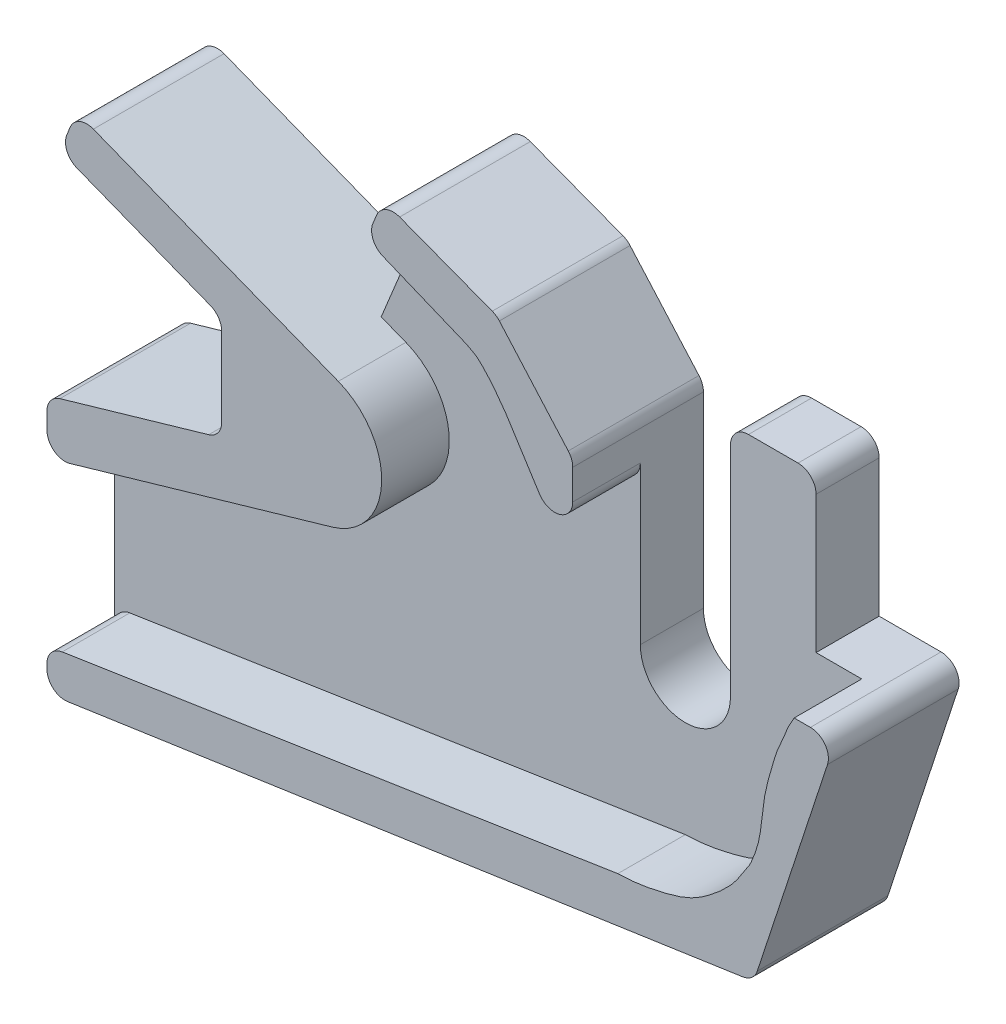
from build123d import *

# Parameters (mm, degrees)
BOSS_EXTRUDE1_DEPTH = 7
BOSS_EXTRUDE2_DEPTH = 14.5
FILLET1_R           = 2


with BuildPart() as part:
    # Sketch1 → Boss-Extrude1 (new body)
    with BuildSketch(Plane.XY):
        with BuildLine():
            Line((78.968274755, 42.187825254), (71.540745427, 53.865587102))
            add(Edge.make_bspline(
                [(68.390340924, 57.620496538), (68.602709936, 57.450222077), (69.775890669, 56.287697417), (70.767112906, 54.998035869), (71.540745427, 53.865587102)],
                knots=[0.224190465, 0.224190465, 0.224190465, 0.224190465, 0.35338295, 1, 1, 1, 1], degree=3))
            add(Edge.make_bspline(
                [(67.166812946, 58.333047532), (67.530665789, 58.148158455), (67.965619608, 57.94613578), (68.341003199, 57.660054826), (68.390340924, 57.620496538)],
                knots=[0, 0, 0, 0, 0.194176372, 0.224190465, 0.224190465, 0.224190465, 0.224190465], degree=3))
            Line((67.166812946, 58.333047532), (56.038116318, 62.903316899))
            Line((56.038116318, 62.903316899), (50.212333598, 48.717420333))
            Line((50.212333598, 48.717420333), (52.954647131, 47.643030748))
            ThreePointArc((52.954647131, 47.643030748), (57.760447877, 40.242237766), (52.301439007, 33.309224011))
            Line((52.301439007, 33.309224011), (20.622854325, 24.120186594))
            Line((20.622854325, 24.120186594), (20.622821101, 6.139939904))
            Line((20.622821101, 6.139939904), (20.622821101, 6.062388022))
            Line((20.622821101, 6.062388022), (83.968274755, 15.843555634))
            add(Edge.make_bspline(
                [(83.968274755, 15.843555634), (85.800365799, 15.861062532), (88.173725783, 16.289321284), (90.975797999, 17.070964386), (92.71201966, 17.824393939), (94.432142997, 19.052982354), (96.042680501, 20.454120962), (97.16419489, 21.752212783), (97.85208587, 22.923017738), (98.591547775, 23.89563478), (99.076744993, 25.078186891), (99.653721004, 26.703400446), (99.922417932, 28.680656555), (100.145652546, 30.848800013), (100.518866207, 32.862374789), (101.110135911, 34.645256352), (101.507154147, 36.227897201), (102.065937234, 37.400646368), (102.486280277, 38.406589289), (102.848421122, 39.429390424), (103.210900567, 39.990397653), (103.388377927, 40.31628874)],
                knots=[0, 0, 0, 0, 0.157855041, 0.207039447, 0.25109495, 0.320551145, 0.388512016, 0.435360012, 0.467800808, 0.505699215, 0.54027798, 0.577572476, 0.654531679, 0.711416671, 0.766136786, 0.830869277, 0.873613049, 0.906584734, 0.942749871, 0.967881323, 1, 1, 1, 1], degree=3))
            Line((103.388377927, 40.31628874), (103.535345735, 40.584708371))
            Line((103.535345735, 40.584708371), (98.468274755, 40.584708371))
            Line((98.468274755, 40.584708371), (98.468274755, 57.798688379))
            Line((98.468274755, 57.798688379), (88.968274755, 57.798688379))
            Line((88.968274755, 57.798688379), (88.968274755, 31.593555634))
            ThreePointArc((88.968274755, 31.593555634), (83.968274755, 26.593555634), (78.968274755, 31.593555634))
            Line((78.968274755, 31.593555634), (78.968274755, 42.187825254))
        make_face()
    extrude(amount=BOSS_EXTRUDE1_DEPTH)

    # Sketch1_3 → Boss-Extrude2 (add)
    with BuildSketch(Plane.XY):
        with BuildLine():
            Line((78.968274755, 42.187825254), (78.968274755, 53.145980791))
            Line((78.968274755, 53.145980791), (70.500822854, 62.754302183))
            Line((70.500822854, 62.754302183), (57.937552223, 67.52848103))
            Line((57.937552223, 67.52848103), (56.038116318, 62.903316899))
            Line((56.038116318, 62.903316899), (67.166812946, 58.333047532))
            add(Edge.make_bspline(
                [(67.166812946, 58.333047532), (67.530665789, 58.148158455), (68.216267043, 57.829717754), (69.737542808, 56.337591135), (70.767112906, 54.998035869), (71.540745427, 53.865587102)],
                knots=[0, 0, 0, 0, 0.194176372, 0.35338295, 1, 1, 1, 1], degree=3))
            Line((71.540745427, 53.865587102), (78.968274755, 42.187825254))
        make_face()
        with BuildLine():
            Line((108.098254598, 40.584708371), (103.535345735, 40.584708371))
            Line((103.535345735, 40.584708371), (103.388377927, 40.31628874))
            add(Edge.make_bspline(
                [(83.968274755, 15.843555634), (85.800365799, 15.861062532), (88.173725783, 16.289321284), (90.975797999, 17.070964386), (92.71201966, 17.824393939), (94.432142997, 19.052982354), (96.042680501, 20.454120962), (97.16419489, 21.752212783), (97.85208587, 22.923017738), (98.591547775, 23.89563478), (99.076744993, 25.078186891), (99.653721004, 26.703400446), (99.922417932, 28.680656555), (100.145652546, 30.848800013), (100.518866207, 32.862374789), (101.110135911, 34.645256352), (101.507154147, 36.227897201), (102.065937234, 37.400646368), (102.486280277, 38.406589289), (102.848421122, 39.429390424), (103.210900567, 39.990397653), (103.388377927, 40.31628874)],
                knots=[0, 0, 0, 0, 0.157855041, 0.207039447, 0.25109495, 0.320551145, 0.388512016, 0.435360012, 0.467800808, 0.505699215, 0.54027798, 0.577572476, 0.654531679, 0.711416671, 0.766136786, 0.830869277, 0.873613049, 0.906584734, 0.942749871, 0.967881323, 1, 1, 1, 1], degree=3))
            Line((83.968274755, 15.843555634), (20.622821101, 6.062388022))
            Line((20.622821101, 6.062388022), (20.622821101, 1.512651605))
            Line((20.622821101, 1.512651605), (99.055701616, 13.03519587))
            Line((99.055701616, 13.03519587), (108.098254598, 40.584708371))
        make_face()
        with BuildLine():
            Line((52.954647131, 47.643030748), (23.913290613, 59.020916827))
            Line((23.913290613, 59.020916827), (22.089364871, 54.365458215))
            Line((22.089364871, 54.365458215), (40.019787084, 47.340638243))
            Line((40.019787084, 47.340638243), (40.019787084, 35.746673468))
            Line((40.019787084, 35.746673468), (20.622854325, 30.120186594))
            Line((20.622854325, 30.120186594), (20.622854325, 24.120186594))
            Line((20.622854325, 24.120186594), (52.301439007, 33.309224011))
            ThreePointArc((52.301439007, 33.309224011), (57.760447877, 40.242237766), (52.954647131, 47.643030748))
        make_face()
    extrude(amount=BOSS_EXTRUDE2_DEPTH)

    # Fillet1
    fillet1_edges = [part.edges().sort_by_distance(p)[0] for p in [
        (78.968274755, 53.145980791, 7.25),
        (70.500822854, 62.754302183, 7.25),
        (99.055701616, 13.03519587, 7.25),
        (108.098254598, 40.584708371, 7.25),
        (98.468274755, 57.798688379, 3.5),
        (88.968274755, 57.798688379, 3.5),
        (57.937552223, 67.52848103, 7.25),
        (56.038116318, 62.903316899, 10.75),
        (78.968274755, 42.187825254, 10.75),
        (20.622821101, 1.512651605, 7.25),
        (20.622854325, 24.120186594, 10.75),
        (20.622854325, 30.120186594, 7.25),
        (23.913290613, 59.020916827, 7.25),
        (22.089364871, 54.365458215, 7.25),
        (40.019787084, 47.340638243, 7.25),
        (40.019787084, 35.746673468, 7.25),
        (20.622821101, 6.062388022, 10.75),
    ]]
    fillet(fillet1_edges, radius=FILLET1_R)


solid = part.part
